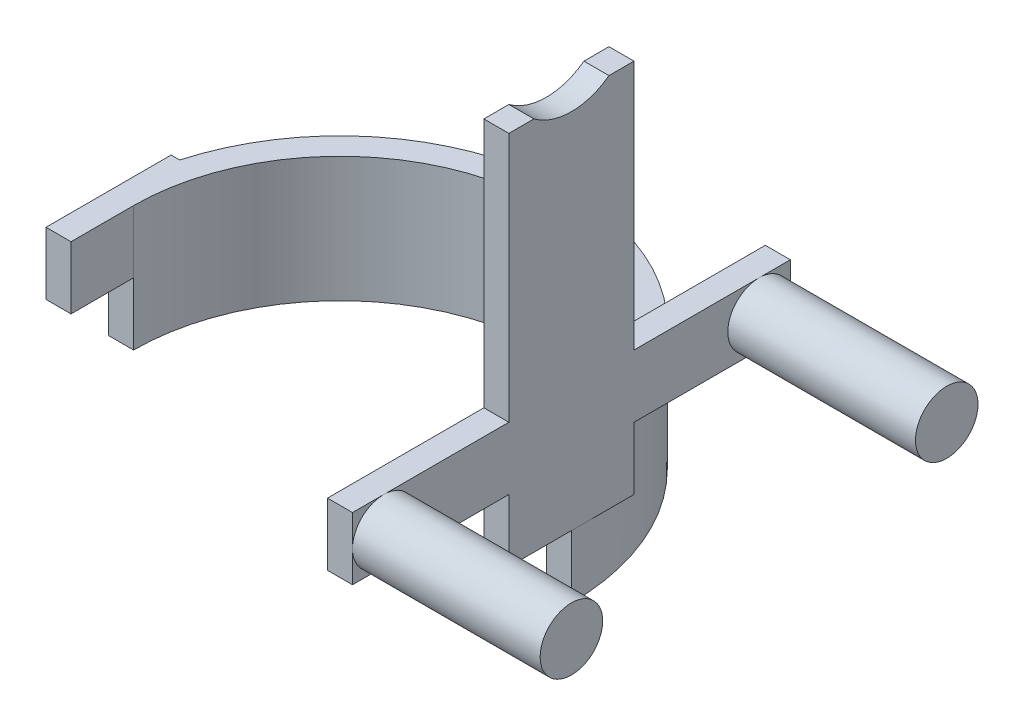
from build123d import *

# Parameters (mm, degrees)
EXTRUDE_1_DEPTH     = 40
SKETCH_2_W          = 8
SKETCH_2_H          = 40
EXTRUDE_2_DEPTH     = 100
SKETCH_3_R          = 20
CUT_EXTRUDE_1_DEPTH = 149
SKETCH_4_W          = 49.783903804
SKETCH_4_H          = 113.982309312
CUT_EXTRUDE_3_DEPTH = 10
SKETCH_5_R          = 84.762192866
CUT_EXTRUDE_4_DEPTH = 20
SKETCH_6_W          = 140
SKETCH_6_H          = 20
EXTRUDE_3_DEPTH     = 8
SKETCH_7_R          = 10
EXTRUDE_4_DEPTH     = 60


with BuildPart() as part:
    # 草图1 → 凸台-拉伸1 (new body)
    with BuildSketch(Plane(origin=(0, 0, 0), x_dir=(1, 0, 0), z_dir=(0, 1, 0))):
        with BuildLine():
            Line((-74, 20), (-71.246052522, 20))
            ThreePointArc((-71.246052522, 20), (0, 74), (71.246052522, 20))
            Line((71.246052522, 20), (74, 20))
            Line((74, 20), (74, -20))
            Line((74, -20), (66, -20))
            Line((66, -20), (66, 0))
            ThreePointArc((66, 0), (0, 66), (-66, 0))
            Line((-66, 0), (-66, -20))
            Line((-66, -20), (-74, -20))
            Line((-74, -20), (-74, 20))
        make_face()
    extrude(amount=EXTRUDE_1_DEPTH)

    # 草图2 → 凸台-拉伸2 (add)
    with BuildSketch(Plane(origin=(0, 40, 0), x_dir=(1, 0, 0), z_dir=(0, 1, 0))):
        with Locations((-70, 0)):
            Rectangle(SKETCH_2_W, SKETCH_2_H)
        with Locations((70, 0)):
            Rectangle(SKETCH_2_W, SKETCH_2_H)
    extrude(amount=EXTRUDE_2_DEPTH)

    # 草图3 → 切除-拉伸1 (cut, through all)
    with BuildSketch(Plane.ZY.offset(74)):
        with Locations((0, 156)):
            Circle(SKETCH_3_R)
    extrude(amount=-CUT_EXTRUDE_1_DEPTH, mode=Mode.SUBTRACT)

    # 草图4 → 切除-拉伸3 (cut)
    with BuildSketch(Plane.ZY.offset(74)):
        with Locations((4.891951902, 96.991154656)):
            Rectangle(SKETCH_4_W, SKETCH_4_H)
    extrude(amount=-CUT_EXTRUDE_3_DEPTH, mode=Mode.SUBTRACT)

    # 草图5 → 切除-拉伸4 (cut)
    with BuildSketch(Plane.XZ):
        Circle(SKETCH_5_R)
        with BuildLine():
            Line((-71.246052522, 20), (-66, 20))
            Line((-66, 20), (-66, 0))
            Line((-66, 0), (-74, 0))
            ThreePointArc((-74, 0), (0, -74), (74, 0))
            Line((74, 0), (66, 0))
            Line((66, 0), (66, 20))
            Line((66, 20), (71.246052522, 20))
            ThreePointArc((71.246052522, 20), (0, 74), (-71.246052522, 20))
        make_face(mode=Mode.SUBTRACT)
    extrude(amount=-CUT_EXTRUDE_4_DEPTH, mode=Mode.SUBTRACT)

    # 草图6 → 凸台-拉伸3 (add)
    with BuildSketch(Plane(origin=(74, 0, 0), x_dir=(0, 0, -1), z_dir=(1, 0, 0))):
        with Locations((0, 50)):
            Rectangle(SKETCH_6_W, SKETCH_6_H)
    extrude(amount=-EXTRUDE_3_DEPTH)

    # 草图7 → 凸台-拉伸4 (add)
    with BuildSketch(Plane(origin=(74, 0, 0), x_dir=(0, 0, -1), z_dir=(1, 0, 0))):
        with Locations((-60, 50)):
            Circle(SKETCH_7_R)
        with Locations((60, 50)):
            Circle(SKETCH_7_R)
    extrude(amount=EXTRUDE_4_DEPTH)


solid = part.part
